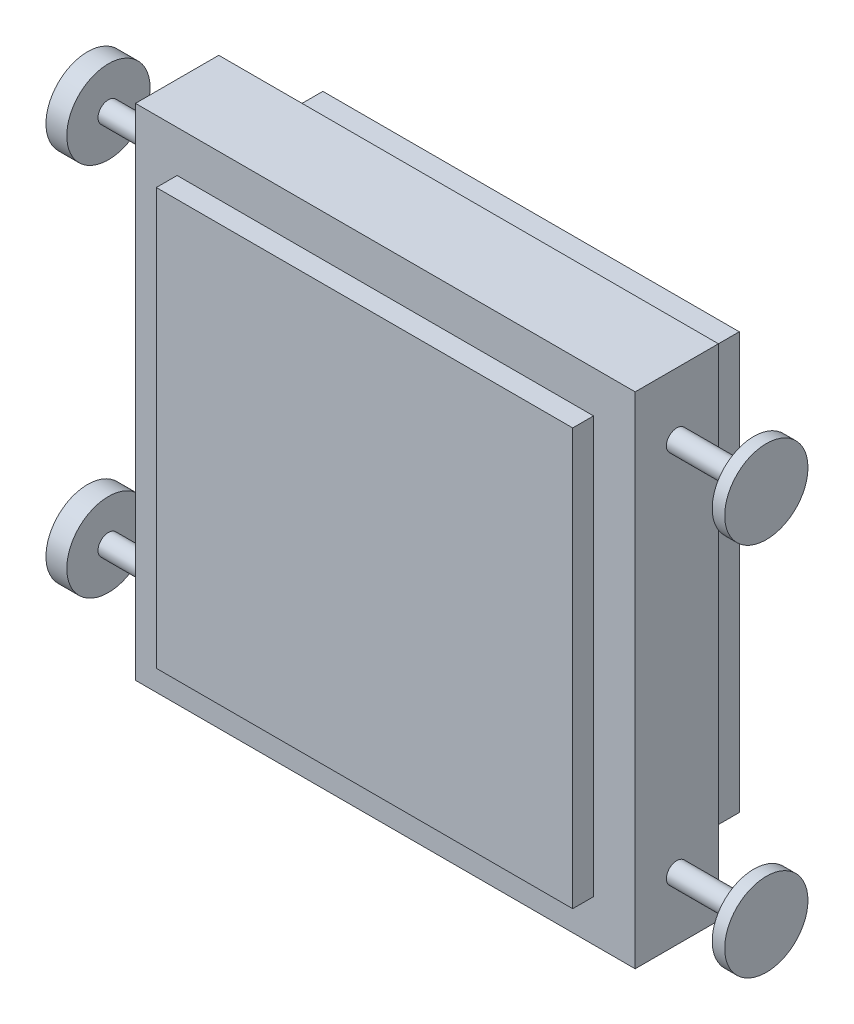
from build123d import *

# Parameters (mm, degrees)
SKETCH_1_W      = 800
SKETCH_1_H      = 800
EXTRUDE_1_DEPTH = 100
EXTRUDE_START   = 25
SKETCH_2_W      = 1000
SKETCH_2_H      = 1000
EXTRUDE_2_DEPTH = 400
EXTRUDE_START_2 = 175
SKETCH_2_3_W    = 1200
SKETCH_2_3_H    = 1200
SKETCH_2_3_W_2  = 1000
SKETCH_2_3_H_2  = 1000
EXTRUDE_3_DEPTH = 200
SKETCH_4_R      = 25
EXTRUDE_4_DEPTH = 815
EXTRUDE_START_3 = 815
SKETCH_4_3_R    = 100
SKETCH_4_3_R_2  = 25
EXTRUDE_5_DEPTH = 30
EXTRUDE_START_4 = -815
SKETCH_4_4_R    = 100
SKETCH_4_4_R_2  = 25
EXTRUDE_6_DEPTH = 50


with BuildPart() as part:
    # Эскиз1 → Бобышка-Вытянуть1 (new body)
    with BuildSketch(Plane.XY):
        Rectangle(SKETCH_1_W, SKETCH_1_H)
    extrude(amount=EXTRUDE_1_DEPTH)


with BuildPart() as body_2:
    # Эскиз2 → Бобышка-Вытянуть2 (new body)
    with BuildSketch(Plane.XY.offset(EXTRUDE_START)):
        Rectangle(SKETCH_2_W, SKETCH_2_H)
    extrude(amount=EXTRUDE_2_DEPTH)


with BuildPart() as body_3:
    # Эскиз2<3> → Бобышка-Вытянуть3 (new body)
    with BuildSketch(Plane.XY.offset(EXTRUDE_START_2)):
        Rectangle(SKETCH_2_3_W, SKETCH_2_3_H)
        Rectangle(SKETCH_2_3_W_2, SKETCH_2_3_H_2, mode=Mode.SUBTRACT)
    extrude(amount=EXTRUDE_3_DEPTH)

    # Эскиз4 → Бобышка-Вытянуть4 (add, symmetric)
    with BuildSketch(Plane(origin=(0, 0, 0), x_dir=(0, 0, -1), z_dir=(1, 0, 0))):
        with Locations((-275, 450)):
            Circle(SKETCH_4_R)
        with Locations((-275, -450)):
            Circle(SKETCH_4_R)
    extrude(amount=EXTRUDE_4_DEPTH, both=True)

    # Эскиз4<3> → Бобышка-Вытянуть5 (add)
    with BuildSketch(Plane(origin=(0, 0, 0), x_dir=(0, 0, -1), z_dir=(1, 0, 0)).offset(EXTRUDE_START_3)):
        with Locations((-275, -450)):
            Circle(SKETCH_4_3_R)
        with Locations((-275, -450)):
            Circle(SKETCH_4_3_R_2, mode=Mode.SUBTRACT)
        with Locations((-275, 450)):
            Circle(SKETCH_4_3_R)
        with Locations((-275, 450)):
            Circle(SKETCH_4_3_R_2, mode=Mode.SUBTRACT)
    extrude(amount=-EXTRUDE_5_DEPTH)

    # Эскиз4<4> → Бобышка-Вытянуть6 (add)
    with BuildSketch(Plane(origin=(0, 0, 0), x_dir=(0, 0, -1), z_dir=(1, 0, 0)).offset(EXTRUDE_START_4)):
        with Locations((-275, -450)):
            Circle(SKETCH_4_4_R)
        with Locations((-275, -450)):
            Circle(SKETCH_4_4_R_2, mode=Mode.SUBTRACT)
        with Locations((-275, 450)):
            Circle(SKETCH_4_4_R)
        with Locations((-275, 450)):
            Circle(SKETCH_4_4_R_2, mode=Mode.SUBTRACT)
    extrude(amount=EXTRUDE_6_DEPTH)


solid = Compound([part.part, body_2.part, body_3.part])
